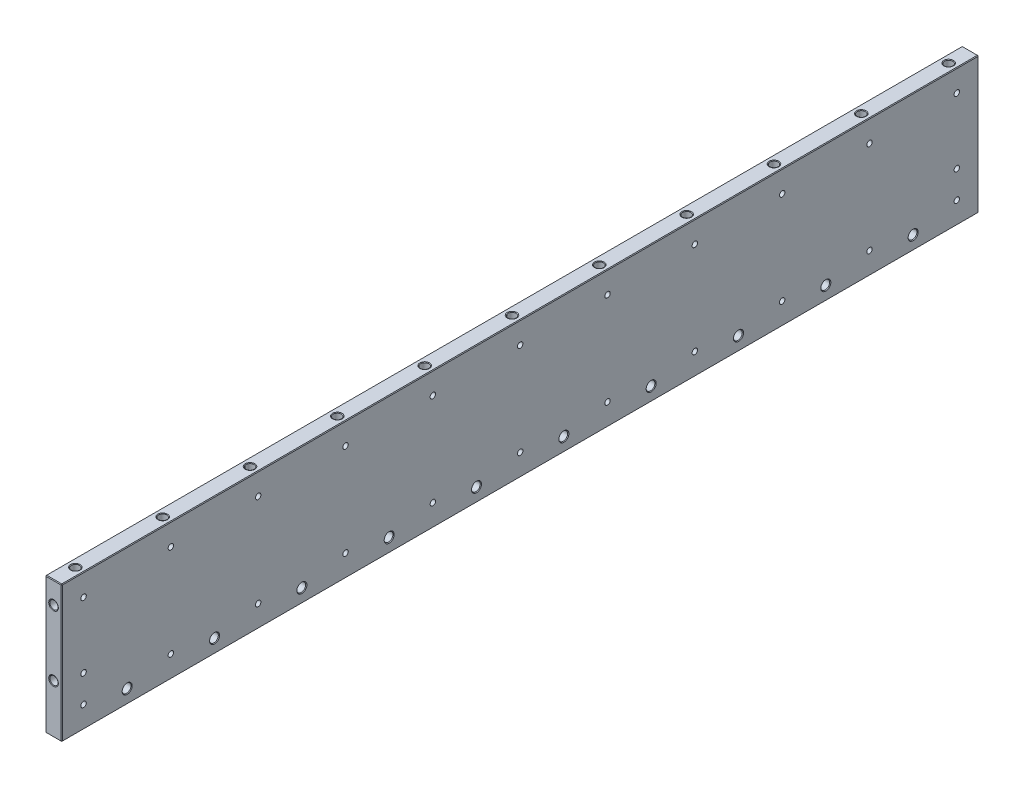
from build123d import *

# Parameters (mm, degrees)
SKETCH1_W                        = 19.05
SKETCH1_H                        = 158.75
BASE_EXTRUDE_DEPTH               = 533.4
F_1_4_0_25_VENT_HOLE_D           = 6.35
LPATTERN1_COUNT                  = 6
LPATTERN1_PITCH                  = 101.6
LPATTERN1_COL_COUNT              = 6
LPATTERN1_COL_PITCH              = 101.6
LPATTERN2_COUNT                  = 6
LPATTERN2_PITCH                  = 101.6
LPATTERN2_COL_COUNT              = 5
LPATTERN2_COL_PITCH              = 101.6
F_3_8_16_TAPPED_HOLE2_AT_2_COUNT = 2
F_3_8_16_TAPPED_HOLE2_AT_2_PITCH = 76.2
F_1_4_0_25_DIAMETER_HOLE2_D      = 6.35
CHAMFER1_SIZE                    = 0.762


with BuildPart() as part:
    # Sketch1 → Base-Extrude (new body, symmetric)
    with BuildSketch(Plane.XY):
        with Locations((0, -79.375)):
            Rectangle(SKETCH1_W, SKETCH1_H)
    extrude(amount=BASE_EXTRUDE_DEPTH, both=True)

    # Sketch2 → 3_8-16 Tapped Hole1 (revolve, cut)
    with BuildSketch(Plane(origin=(0, 0, 0), x_dir=(0, 0, 1), z_dir=(1, 0, 0))):
        Polygon((0, 0), (0, 27.784665582), (3.96875, 25.4), (3.96875, 19.05), (4.7625, 19.05), (4.7625, 0.476602647), (5.588, 0), align=None)
    f_3_8_16_tapped_hole1 = revolve(axis=Axis((0, 6.35, 0), (0, -1, 0)), mode=Mode.SUBTRACT)

    # Sketch17 → 3_8-16 Tapped Hole3 (revolve, cut)
    with BuildSketch(Plane(origin=(0, -158.75, 0), x_dir=(0, 0, -1), z_dir=(1, 0, 0))):
        Polygon((0, 0), (0, 27.784665582), (3.96875, 25.4), (3.96875, 19.05), (4.7625, 19.05), (4.7625, 0.476602647), (5.588, 0), align=None)
    f_3_8_16_tapped_hole3 = revolve(axis=Axis((0, -165.1, 0), (0, 1, 0)), mode=Mode.SUBTRACT)

    # 1_4 _0.25_ Vent Hole (through all)
    with Locations(Plane(origin=(9.525, 0, 0), x_dir=(0, 0, -1), z_dir=(1, 0, 0))):
        with Locations((0, -25.4), (0, -133.35)):
            f_1_4_0_25_vent_hole = Hole(F_1_4_0_25_VENT_HOLE_D / 2)

    # LPattern1: 3_8-16 Tapped Hole1, 3_8-16 Tapped Hole3, 1_4 _0.25_ Vent Hole ×6
    with Locations(*[(0, 0, -i * LPATTERN1_PITCH) for i in range(1, LPATTERN1_COUNT)]):
        add(f_3_8_16_tapped_hole1, mode=Mode.SUBTRACT)
        add(f_3_8_16_tapped_hole3, mode=Mode.SUBTRACT)
        add(f_1_4_0_25_vent_hole, mode=Mode.SUBTRACT)

    # LPattern1 col: 3_8-16 Tapped Hole1, 3_8-16 Tapped Hole3, 1_4 _0.25_ Vent Hole ×6
    with Locations(*[(0, 0, i * LPATTERN1_COL_PITCH) for i in range(1, LPATTERN1_COL_COUNT)]):
        add(f_3_8_16_tapped_hole1, mode=Mode.SUBTRACT)
        add(f_3_8_16_tapped_hole3, mode=Mode.SUBTRACT)
        add(f_1_4_0_25_vent_hole, mode=Mode.SUBTRACT)

    # Sketch4 → 3_8 Clearance Hole1 (revolve, cut)
    with BuildSketch(Plane(origin=(9.525, -142.875, 50.8), x_dir=(0, 0, -1), z_dir=(0, 1, 0))):
        Polygon((0, 0), (0, 19.05), (5.842, 19.05), (5.15874, 18.263999282), (5.15874, 0.786000718), (5.842, 0), align=None)
    f_3_8_clearance_hole1 = revolve(axis=Axis((15.875, -142.875, 50.8), (-1, 0, 0)), mode=Mode.SUBTRACT)

    # LPattern2: 3_8 Clearance Hole1 ×6
    with Locations(*[(0, 0, -i * LPATTERN2_PITCH) for i in range(1, LPATTERN2_COUNT)]):
        add(f_3_8_clearance_hole1, mode=Mode.SUBTRACT)

    # LPattern2 col: 3_8 Clearance Hole1 ×5
    with Locations(*[(0, 0, i * LPATTERN2_COL_PITCH) for i in range(1, LPATTERN2_COL_COUNT)]):
        add(f_3_8_clearance_hole1, mode=Mode.SUBTRACT)

    # Sketch6 → 3_8-16 Tapped Hole2 (revolve, cut)
    with BuildSketch(Plane(origin=(0, -25.4, 533.4), x_dir=(0, -1, 0), z_dir=(1, 0, 0))):
        Polygon((0, 0), (0, 27.784665582), (3.96875, 25.4), (3.96875, 19.05), (4.7625, 19.05), (4.7625, 0.476602647), (5.588, 0), align=None)
    f_3_8_16_tapped_hole2 = revolve(axis=Axis((0, -25.4, 539.75), (0, 0, -1)), mode=Mode.SUBTRACT)

    # 3_8-16 Tapped Hole2 at 2: 3_8-16 Tapped Hole2 ×2
    with Locations(*[(0, -i * F_3_8_16_TAPPED_HOLE2_AT_2_PITCH, 0) for i in range(1, F_3_8_16_TAPPED_HOLE2_AT_2_COUNT)]):
        add(f_3_8_16_tapped_hole2, mode=Mode.SUBTRACT)

    # Mirror2: 3_8-16 Tapped Hole2 across plane
    add(f_3_8_16_tapped_hole2.mirror(Plane.XY), mode=Mode.SUBTRACT)

    # Mirror2 copy 1 sketch → Mirror2 copy 1 (revolve, cut)
    with BuildSketch(Plane(origin=(0, -101.6, -533.4), x_dir=(0, -1, 0), z_dir=(1, 0, 0))):
        Polygon((0, 0), (0, -27.784665582), (3.96875, -25.4), (3.96875, -19.05), (4.7625, -19.05), (4.7625, -0.476602647), (5.588, 0), align=None)
    revolve(axis=Axis((0, -101.6, -539.75), (0, 0, -1)), mode=Mode.SUBTRACT)

    # 1_4 _0.25_ Diameter Hole2 (through all)
    with Locations(Plane(origin=(9.525, 0, 0), x_dir=(0, 0, -1), z_dir=(1, 0, 0))):
        with Locations((-508, -101.6)):
            f_1_4_0_25_diameter_hole2 = Hole(F_1_4_0_25_DIAMETER_HOLE2_D / 2)

    # Mirror3: 1_4 _0.25_ Diameter Hole2 across plane
    add(f_1_4_0_25_diameter_hole2.mirror(Plane.XY), mode=Mode.SUBTRACT)

    # Chamfer1
    chamfer1_edges = [part.edges().sort_by_distance(p)[0] for p in [
        (9.525, -79.375, 533.4),
        (0, 0, 533.4),
        (-9.525, -79.375, 533.4),
        (0, 0, -533.4),
        (9.525, -79.375, -533.4),
        (0, -158.75, -533.4),
        (-9.525, -79.375, -533.4),
        (0, -158.75, 533.4),
        (-9.525, 0, 0),
        (9.525, 0, 0),
        (9.525, -158.75, 0),
        (-9.525, -158.75, 0),
    ]]
    chamfer(chamfer1_edges, length=CHAMFER1_SIZE)


solid = part.part
